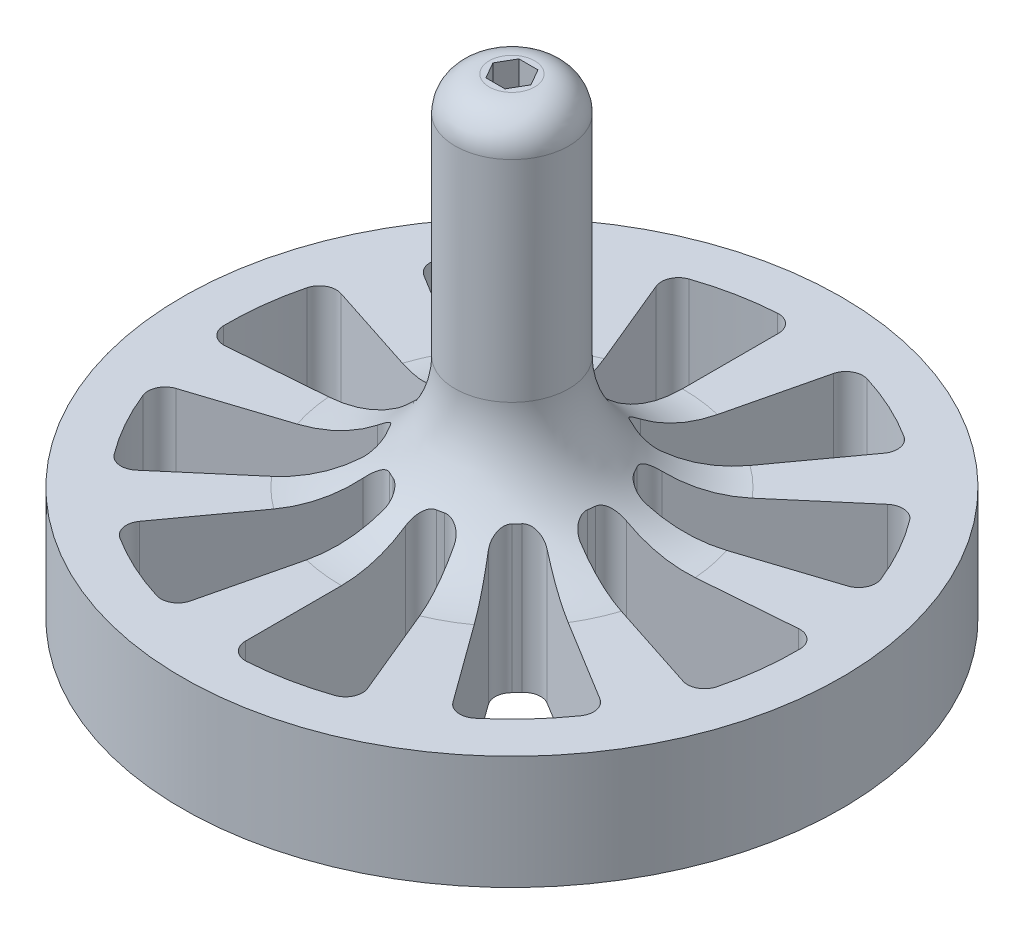
from build123d import *

# Parameters (mm, degrees)
WYTNIJ_WYCI_GNI_CIE1_DEPTH = 41.5
ZAOKR_GLENIE1_R            = 3
WYTNIJ_WYCI_GNI_CIE2_DEPTH = 42.5
SZYK_KO_OWY1_COUNT         = 10


with BuildPart() as part:
    # Szkic1 → Obrót1 (revolve)
    with BuildSketch(Plane.XY):
        with BuildLine():
            Line((29, 10), (15, 10))
            ThreePointArc((15, 10), (7.928932188, 12.928932188), (5, 20))
            Line((5, 20), (5, 41.5))
            Line((5, 41.5), (0, 41.5))
            Line((0, 41.5), (0, 0))
            Line((0, 0), (29, 0))
            Line((29, 0), (29, 10))
        make_face()
    revolve(axis=Axis((0, 0, 0), (0, 1, 0)))

    # Szkic2 → Wytnij-wyciągnięcie1 (cut)
    with BuildSketch(Plane.XZ):
        Polygon((1.674315781, 0), (0.83715789, 1.45), (-0.83715789, 1.45), (-1.674315781, 0), (-0.83715789, -1.45), (0.83715789, -1.45), align=None)
    extrude(amount=-WYTNIJ_WYCI_GNI_CIE1_DEPTH, mode=Mode.SUBTRACT)

    # Zaokrąglenie1
    zaokr_glenie1_edges = [part.edges().sort_by_distance(p)[0] for p in [
        (-5, 41.5, 0),
    ]]
    fillet(zaokr_glenie1_edges, radius=ZAOKR_GLENIE1_R)

    # Szkic4 → Wytnij-wyciągnięcie2 (cut, through all)
    with BuildSketch(Plane.XZ):
        with BuildLine():
            Line((0, 23.452078799), (0, 9.38083152))
            ThreePointArc((0, 9.38083152), (0.358671135, 8.407502993), (1.263157895, 7.899647595))
            ThreePointArc((1.263157895, 7.899647595), (1.560722576, 7.846282243), (1.856058531, 7.781712326))
            ThreePointArc((1.856058531, 7.781712326), (2.886043183, 7.904777436), (3.589888804, 8.666758239))
            Line((3.589888804, 8.666758239), (8.974722011, 21.666895597))
            ThreePointArc((8.974722011, 21.666895597), (8.955686042, 22.858904022), (8.073300758, 23.660553985))
            ThreePointArc((8.073300758, 23.660553985), (4.87725805, 24.51963201), (1.595744681, 24.949019999))
            ThreePointArc((1.595744681, 24.949019999), (0.473748818, 24.546066235), (0, 23.452078799))
        make_face()
    wytnij_wyci_gni_cie2 = extrude(amount=-WYTNIJ_WYCI_GNI_CIE2_DEPTH, mode=Mode.SUBTRACT)

    # Szyk kołowy1: Wytnij-wyciągnięcie2 ×10 about axis
    szyk_ko_owy1_axis = Axis((0, 0, 0), (0, 1, 0))
    for i in range(1, SZYK_KO_OWY1_COUNT):
        add(wytnij_wyci_gni_cie2.rotate(szyk_ko_owy1_axis, i * 360 / SZYK_KO_OWY1_COUNT), mode=Mode.SUBTRACT)


solid = part.part
